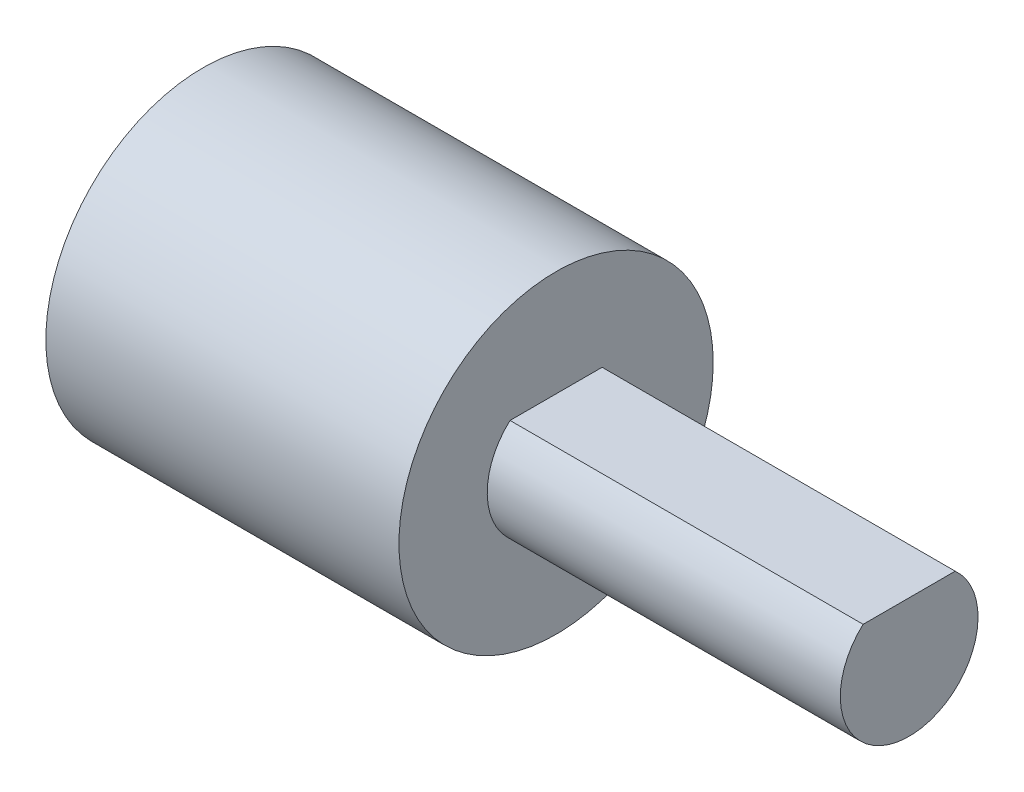
from build123d import *

# Parameters (mm, degrees)
BOSS_EXTRUDE1_DEPTH = 10
SKETCH1_3_R         = 4.45
BOSS_EXTRUDE2_DEPTH = 10


with BuildPart() as part:
    # Sketch1 → Boss-Extrude1 (new body)
    with BuildSketch(Plane(origin=(0, 0, 0), x_dir=(0, 0, -1), z_dir=(1, 0, 0))):
        with BuildLine():
            Line((1.303840481, 1.45), (-1.303840481, 1.45))
            ThreePointArc((-1.303840481, 1.45), (-0.793728878, -1.78114976), (1.95, 0))
            ThreePointArc((1.95, 0), (1.78114976, 0.793728878), (1.303840481, 1.45))
        make_face()
    extrude(amount=BOSS_EXTRUDE1_DEPTH)

    # Sketch1_3 → Boss-Extrude2 (add)
    with BuildSketch(Plane(origin=(0, 0, 0), x_dir=(0, 0, -1), z_dir=(1, 0, 0))):
        Circle(SKETCH1_3_R)
    extrude(amount=-BOSS_EXTRUDE2_DEPTH)


solid = part.part
